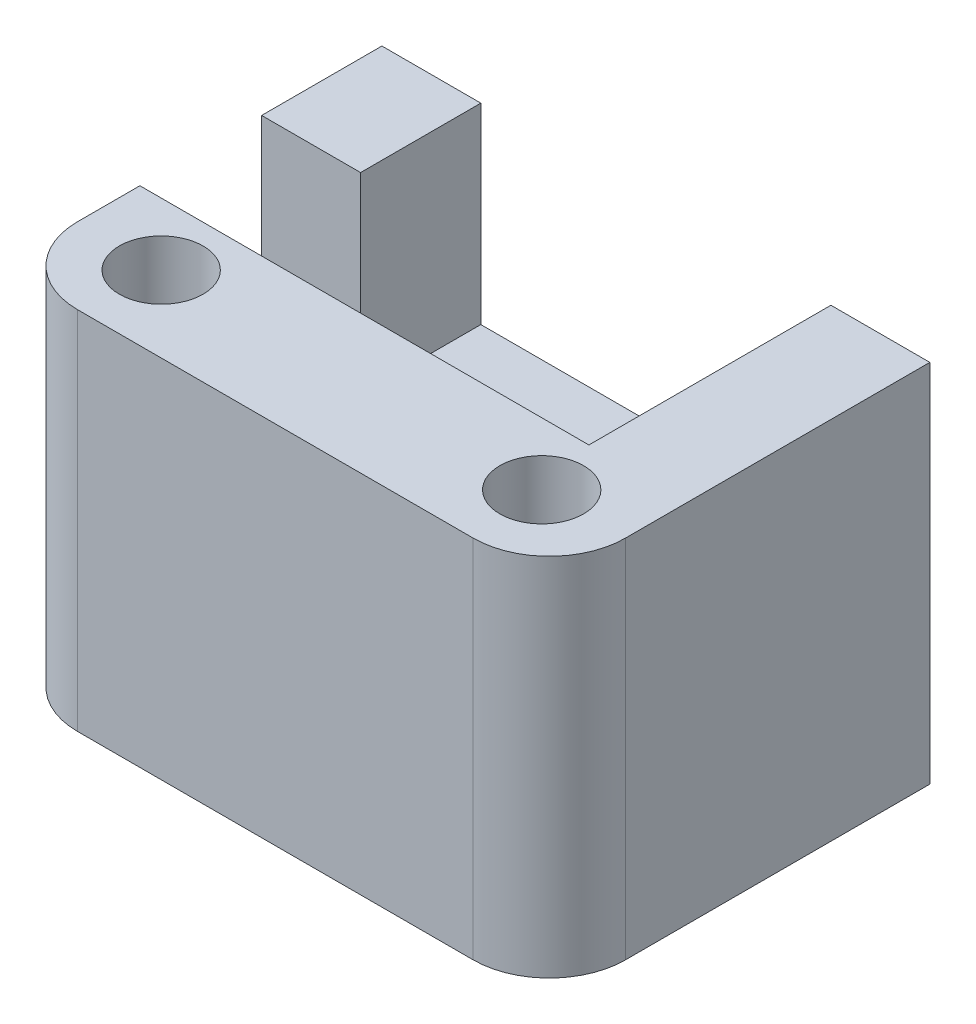
from build123d import *

# Parameters (mm, degrees)
SKETCH2_W                          = 36
SKETCH2_H                          = 25
BOSS_EXTRUDE1_DEPTH                = 24
CUT_EXTRUDE1_DEPTH                 = 12.6
TAP_DRILL_FOR_M2_5X0_45_TAP1_D     = 2.05
TAP_DRILL_FOR_M2_5X0_45_TAP1_DEPTH = 6
FILLET2_R                          = 5
CBORE_FOR_M2_5_SHCS1_D             = 3
CBORE_FOR_M2_5_SHCS1_CBORE_D       = 5.5
CBORE_FOR_M2_5_SHCS1_CBORE_DEPTH   = 4
SKETCH8_W                          = 8
SKETCH8_H                          = 10
CUT_EXTRUDE2_DEPTH                 = 10
FILLET3_R                          = 5


with BuildPart() as part:
    # Sketch2 → Boss-Extrude1 (new body)
    with BuildSketch(Plane(origin=(0, 0, 0), x_dir=(1, 0, 0), z_dir=(0, 1, 0))):
        with Locations((18, 12.5)):
            Rectangle(SKETCH2_W, SKETCH2_H)
    extrude(amount=BOSS_EXTRUDE1_DEPTH)

    # Sketch3 → Cut-Extrude1 (cut)
    with BuildSketch(Plane(origin=(0, 24, 0), x_dir=(1, 0, 0), z_dir=(0, 1, 0))):
        Polygon((6.5, 25), (29.5, 25), (29.5, 9.1), (6.5, 9.1), (5.5, 9.1), (5.5, 14.1), (6.5, 14.1), align=None)
    extrude(amount=-CUT_EXTRUDE1_DEPTH, mode=Mode.SUBTRACT)

    # Tap Drill for M2.5x0.45 Tap1
    with Locations(Plane(origin=(0, 0, -25), x_dir=(-1, 0, 0), z_dir=(0, 0, -1))):
        with Locations((-32.5, 17.7), (-3.5, 17.7)):
            Hole(TAP_DRILL_FOR_M2_5X0_45_TAP1_D / 2, depth=TAP_DRILL_FOR_M2_5X0_45_TAP1_DEPTH)

    # Fillet2
    fillet2_edges = [part.edges().sort_by_distance(p)[0] for p in [
        (36, 12, 0),
    ]]
    fillet(fillet2_edges, radius=FILLET2_R)

    # CBORE for M2.5 SHCS1 (through all)
    with Locations(Plane(origin=(0, 24, 0), x_dir=(1, 0, 0), z_dir=(0, 1, 0))):
        with Locations((30.5, 5), (5.5, 5)):
            CounterBoreHole(CBORE_FOR_M2_5_SHCS1_D / 2, CBORE_FOR_M2_5_SHCS1_CBORE_D / 2, CBORE_FOR_M2_5_SHCS1_CBORE_DEPTH)

    # Sketch8 → Cut-Extrude2 (cut)
    with BuildSketch(Plane.ZY):
        with Locations((-13.1, 19)):
            Rectangle(SKETCH8_W, SKETCH8_H)
    extrude(amount=-CUT_EXTRUDE2_DEPTH, mode=Mode.SUBTRACT)

    # Fillet3
    fillet3_edges = [part.edges().sort_by_distance(p)[0] for p in [
        (0, 12, 0),
    ]]
    fillet(fillet3_edges, radius=FILLET3_R)


solid = part.part
